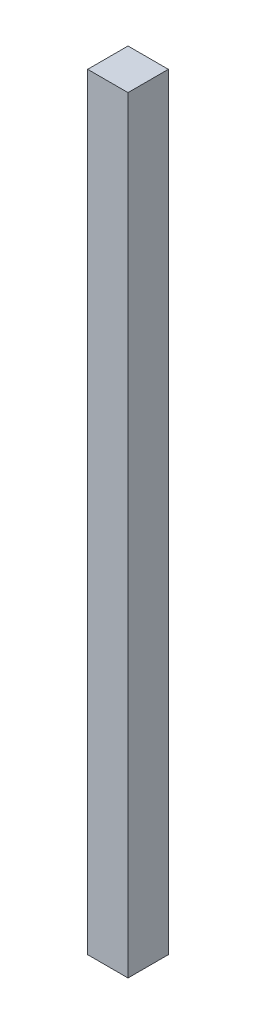
from build123d import *

# Parameters (mm, degrees)
SKETCH1_W           = 3
SKETCH1_H           = 3
BOSS_EXTRUDE1_DEPTH = 57
SCALE1_SCALE        = 10


with BuildPart() as part:
    # Sketch1 → Boss-Extrude1 (new body)
    with BuildSketch(Plane(origin=(0, 0, 0), x_dir=(1, 0, 0), z_dir=(0, 1, 0))):
        Rectangle(SKETCH1_W, SKETCH1_H)
    extrude(amount=BOSS_EXTRUDE1_DEPTH)


with BuildPart() as part_1:
    # Scale1: scaled about (0, 28.5, 0)
    add(part.part.scale(SCALE1_SCALE).moved(Location((0, -256.5, 0))))


solid = part_1.part
